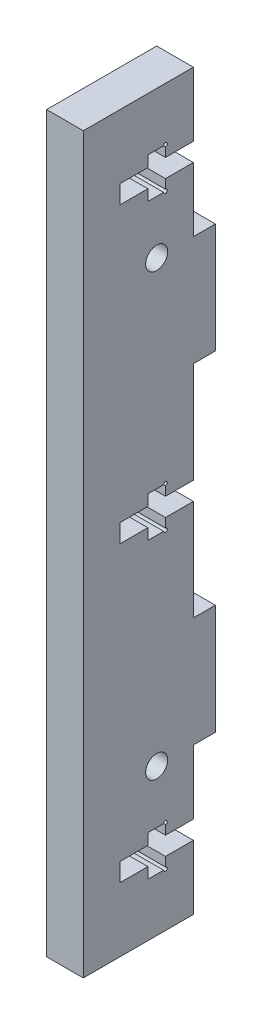
from build123d import *

# Parameters (mm, degrees)
SCHIZZO1_W                   = 15
SCHIZZO1_H                   = 100
ESTRUSIONE_ESTRUSIONE1_DEPTH = 5
SCHIZZO2_W                   = 5
SCHIZZO2_H                   = 15
ESTRUSIONE_ESTRUSIONE2_DEPTH = 3
SCHIZZO4_R                   = 1.5
TAGLIO_ESTRUSIONE2_DEPTH     = 6
TAGLIO_ESTRUSIONE3_DEPTH     = 6
SCHIZZO6_R                   = 0.25
TAGLIO_ESTRUSIONE4_DEPTH     = 10


with BuildPart() as part:
    # Schizzo1 → Estrusione-Estrusione1 (new body)
    with BuildSketch(Plane(origin=(0, 0, 0), x_dir=(0, 0, -1), z_dir=(1, 0, 0))):
        Rectangle(SCHIZZO1_W, SCHIZZO1_H)
    extrude(amount=ESTRUSIONE_ESTRUSIONE1_DEPTH)

    # Schizzo2 → Estrusione-Estrusione2 (add)
    with BuildSketch(Plane(origin=(0, 0, -7.5), x_dir=(-1, 0, 0), z_dir=(0, 0, -1))):
        with Locations((-2.5, 22.5)):
            Rectangle(SCHIZZO2_W, SCHIZZO2_H)
        with Locations((-2.5, -22.5)):
            Rectangle(SCHIZZO2_W, SCHIZZO2_H)
    extrude(amount=ESTRUSIONE_ESTRUSIONE2_DEPTH)

    # Schizzo4 → Taglio-Estrusione2 (cut, through all)
    with BuildSketch(Plane(origin=(0, 0, 0), x_dir=(0, 0, -1), z_dir=(1, 0, 0))):
        with Locations((2.5, 30)):
            Circle(SCHIZZO4_R)
        with Locations((2.5, -30)):
            Circle(SCHIZZO4_R)
    extrude(amount=TAGLIO_ESTRUSIONE2_DEPTH, mode=Mode.SUBTRACT)

    # Schizzo5 → Taglio-Estrusione3 (cut, through all)
    with BuildSketch(Plane(origin=(5, 0, 0), x_dir=(0, 0, -1), z_dir=(1, 0, 0))):
        Polygon((-2.5, 1.25), (1.3, 1.25), (1.3, 2.75), (3.7, 2.75), (3.7, 1.25), (7.5, 1.25), (7.5, -1.25), (3.7, -1.25), (3.7, -2.75), (1.3, -2.75), (1.3, -1.25), (-2.5, -1.25), align=None)
        Polygon((-2.5, -38.75), (1.3, -38.75), (1.3, -37.25), (3.7, -37.25), (3.7, -38.75), (7.5, -38.75), (7.5, -41.25), (3.7, -41.25), (3.7, -42.75), (1.3, -42.75), (1.3, -41.25), (-2.5, -41.25), align=None)
        Polygon((7.5, 38.75), (7.5, 41.25), (3.7, 41.25), (3.7, 42.75), (1.3, 42.75), (1.3, 41.25), (-2.5, 41.25), (-2.5, 38.75), (1.3, 38.75), (1.3, 37.25), (3.7, 37.25), (3.7, 38.75), align=None)
    extrude(amount=-TAGLIO_ESTRUSIONE3_DEPTH, mode=Mode.SUBTRACT)

    # Schizzo6 → Taglio-Estrusione4 (cut)
    with BuildSketch(Plane(origin=(5, 0, 0), x_dir=(0, 0, -1), z_dir=(1, 0, 0))):
        with Locations((3.7, 42.75)):
            Circle(SCHIZZO6_R)
        with Locations((3.7, 37.25)):
            Circle(SCHIZZO6_R)
        with Locations((3.7, 2.75)):
            Circle(SCHIZZO6_R)
        with Locations((3.7, -2.75)):
            Circle(SCHIZZO6_R)
        with Locations((3.7, -37.25)):
            Circle(SCHIZZO6_R)
        with Locations((3.7, -42.75)):
            Circle(SCHIZZO6_R)
    extrude(amount=-TAGLIO_ESTRUSIONE4_DEPTH, mode=Mode.SUBTRACT)


solid = part.part
